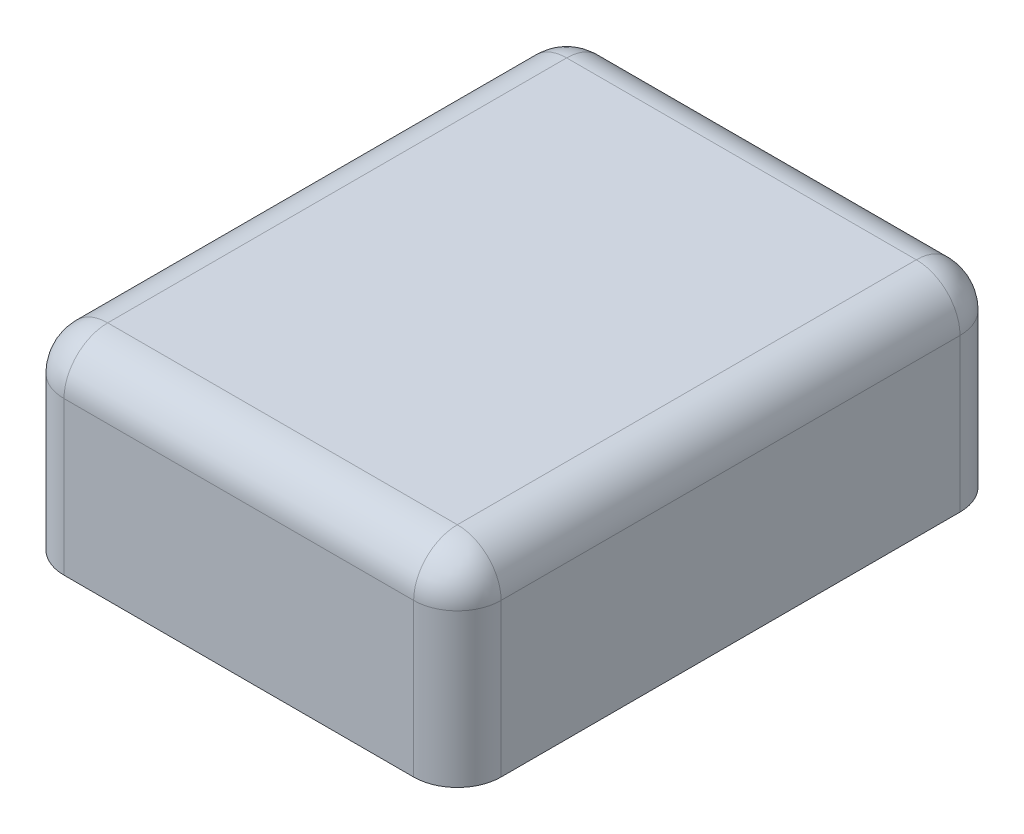
from build123d import *

# Parameters (mm, degrees)
BASES_W    = 2
BASES_H    = 2.5
BASE_DEPTH = 0.9
SIDEF_R    = 0.2
TOPF_R     = 0.2


with BuildPart() as part:
    # BaseS → Base (new body)
    with BuildSketch(Plane(origin=(0, 0, 0), x_dir=(1, 0, 0), z_dir=(0, 1, 0))):
        Rectangle(BASES_W, BASES_H)
    extrude(amount=BASE_DEPTH)

    # SideF
    sidef_edges = [part.edges().sort_by_distance(p)[0] for p in [
        (1, 0.45, 1.25),
        (-1, 0.45, 1.25),
        (-1, 0.45, -1.25),
        (1, 0.45, -1.25),
    ]]
    fillet(sidef_edges, radius=SIDEF_R)

    # TopF
    topf_edges = [part.edges().sort_by_distance(p)[0] for p in [
        (1, 0.9, 0),
        (0, 0.9, 1.25),
        (0, 0.9, -1.25),
        (-1, 0.9, 0),
        (-0.941421356, 0.9, -1.191421356),
        (-0.941421356, 0.9, 1.191421356),
        (0.941421356, 0.9, -1.191421356),
        (0.941421356, 0.9, 1.191421356),
    ]]
    fillet(topf_edges, radius=TOPF_R)


solid = part.part
